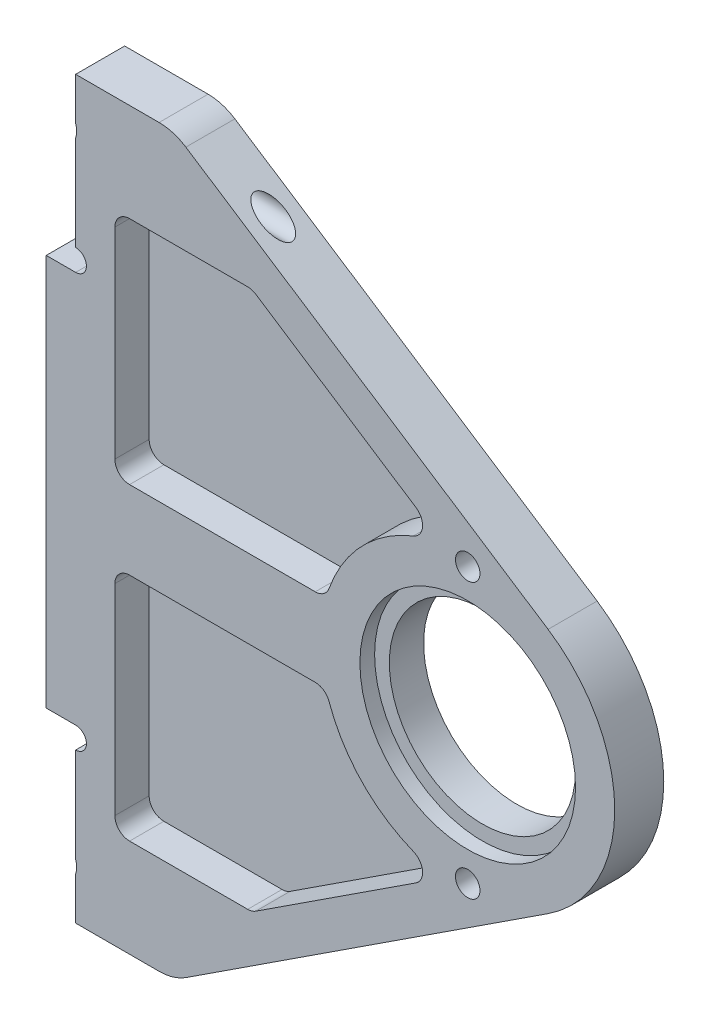
from build123d import *

# Parameters (mm, degrees)
SKETCH_2_W          = 3
SKETCH_2_H          = 40
SKETCH_2_R          = 9.5
SKETCH_2_R_2        = 1.25
EXTRUDE_1_DEPTH     = 5
FILLET_3_R          = 5
SKETCH_3_R          = 1.25
CUT_EXTRUDE_1_DEPTH = 56
SKETCH_4_R          = 1.1
CUT_EXTRUDE_2_DEPTH = 10
SKETCH_5_R          = 2.1
CUT_EXTRUDE_3_DEPTH = 10
SKETCH_7_R          = 11
CUT_EXTRUDE_5_DEPTH = 1.5
CUT_EXTRUDE_6_DEPTH = 3.5
FILLET_5_R          = 1.5


with BuildPart() as part:
    # ｽｹｯﾁ2 → ﾎﾞｽ - 押し出し1 (new body)
    with BuildSketch(Plane.XY):
        with Locations((-41.5, 0)):
            Rectangle(SKETCH_2_W, SKETCH_2_H)
        with BuildLine():
            Line((-40, 37.5), (-40, -37.5))
            Line((-40, -37.5), (-30, -37.5))
            Line((-30, -37.5), (8.20017536, -12.560140288))
            ThreePointArc((8.20017536, -12.560140288), (15, 0), (8.20017536, 12.560140288))
            Line((8.20017536, 12.560140288), (-30, 37.5))
            Line((-30, 37.5), (-40, 37.5))
        make_face()
        Circle(SKETCH_2_R, mode=Mode.SUBTRACT)
        with Locations((0, 14)):
            Circle(SKETCH_2_R_2, mode=Mode.SUBTRACT)
        with Locations((0, -14)):
            Circle(SKETCH_2_R_2, mode=Mode.SUBTRACT)
    extrude(amount=EXTRUDE_1_DEPTH)

    # ﾌｨﾚｯﾄ3
    fillet_3_edges = [part.edges().sort_by_distance(p)[0] for p in [
        (-30, 37.5, 2.5),
        (-30, -37.5, 2.5),
    ]]
    fillet(fillet_3_edges, radius=FILLET_3_R)

    # ｽｹｯﾁ3 → ｶｯﾄ - 押し出し1 (cut, through all)
    with BuildSketch(Plane.ZY.offset(40)):
        with Locations((2.5, -32.5)):
            Circle(SKETCH_3_R)
        with Locations((2.5, 32.5)):
            Circle(SKETCH_3_R)
    extrude(amount=-CUT_EXTRUDE_1_DEPTH, mode=Mode.SUBTRACT)

    # ｽｹｯﾁ4 → ｶｯﾄ - 押し出し2 (cut)
    with BuildSketch(Plane(origin=(0, 0, 0), x_dir=(-1, 0, 0), z_dir=(0, 0, -1))):
        with Locations((40, 21.1)):
            Circle(SKETCH_4_R)
        with Locations((40, -21.1)):
            Circle(SKETCH_4_R)
    extrude(amount=-CUT_EXTRUDE_2_DEPTH, mode=Mode.SUBTRACT)

    # ｽｹｯﾁ5 → ｶｯﾄ - 押し出し3 (cut)
    with BuildSketch(Plane(origin=(0, 0, 0), x_dir=(-1, 0, 0), z_dir=(0, 0, -1))):
        with Locations((42, 32.5)):
            Circle(SKETCH_5_R)
        with Locations((42, -32.5)):
            Circle(SKETCH_5_R)
    extrude(amount=-CUT_EXTRUDE_3_DEPTH, mode=Mode.SUBTRACT)

    # ｽｹｯﾁ7 → ｶｯﾄ - 押し出し5 (cut)
    with BuildSketch(Plane.XY.offset(5)):
        Circle(SKETCH_7_R)
    extrude(amount=-CUT_EXTRUDE_5_DEPTH, mode=Mode.SUBTRACT)

    # ｽｹｯﾁ8 → ｶｯﾄ - 押し出し6 (cut)
    with BuildSketch(Plane.XY.offset(5)):
        with BuildLine():
            Line((-36, -4), (-36, -27.5))
            Line((-36, -27.5), (-22, -27.5))
            Line((-22, -27.5), (-2.525791459, -14.785816768))
            ThreePointArc((-2.525791459, -14.785816768), (-10.059117169, -11.127181214), (-14.456832295, -4))
            Line((-14.456832295, -4), (-36, -4))
        make_face()
        with BuildLine():
            Line((-22, 27.5), (-2.525791459, 14.785816768))
            ThreePointArc((-2.525791459, 14.785816768), (-10.059117169, 11.127181214), (-14.456832295, 4))
            Line((-14.456832295, 4), (-36, 4))
            Line((-36, 4), (-36, 27.5))
            Line((-36, 27.5), (-22, 27.5))
        make_face()
    extrude(amount=-CUT_EXTRUDE_6_DEPTH, mode=Mode.SUBTRACT)

    # ﾌｨﾚｯﾄ5
    fillet_5_edges = [part.edges().sort_by_distance(p)[0] for p in [
        (-36, 27.5, 3.25),
        (-22, 27.5, 3.25),
        (-2.525791459, 14.785816768, 3.25),
        (-14.456832295, 4, 3.25),
        (-36, 4, 3.25),
        (-22, -27.5, 3.25),
        (-36, -27.5, 3.25),
        (-36, -4, 3.25),
        (-14.456832295, -4, 3.25),
        (-2.525791459, -14.785816768, 3.25),
    ]]
    fillet(fillet_5_edges, radius=FILLET_5_R)


solid = part.part
